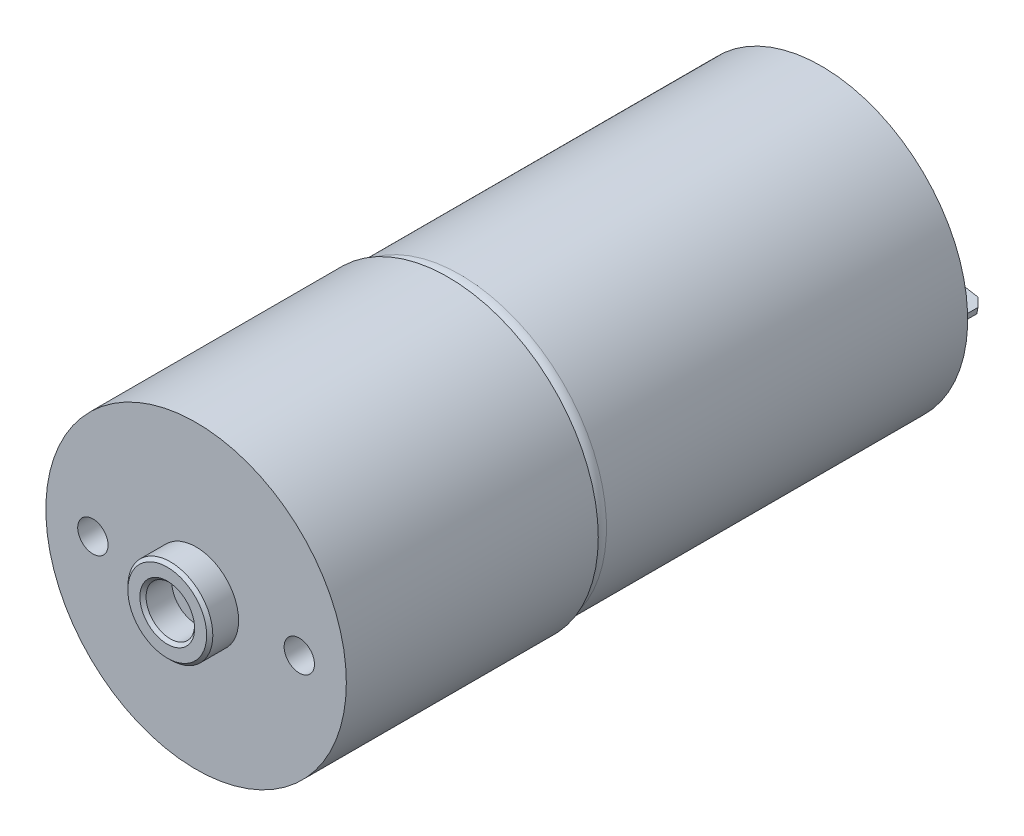
from build123d import *

# Parameters (mm, degrees)
SKETCH1_R                 = 12.05
BOSS_EXTRUDE1_DEPTH       = 30.75
FILLET2_R                 = 1
SKETCH2_R                 = 12.375
BOSS_EXTRUDE2_DEPTH       = 20.75
SKETCH3_R                 = 3.5
SKETCH3_R_2               = 2
BOSS_EXTRUDE3_DEPTH       = 2.375
CHAMFER1_SIZE             = 0.254
M3X0_5_TAPPED_HOLE1_D     = 2.5
M3X0_5_TAPPED_HOLE1_DEPTH = 7.5
M3X0_5_TAPPED_HOLE1_TIP   = 0.751075774
SKETCH7_R                 = 11.8
CUT_EXTRUDE1_DEPTH        = 0.762
SKETCH8_R                 = 4.5
BOSS_EXTRUDE4_DEPTH       = 0.254
BOSS_EXTRUDE4_TAPER       = 60
SKETCH9_R                 = 3.1875
BOSS_EXTRUDE5_DEPTH       = 2.413
FILLET1_R                 = 0.254
SKETCH10_R                = 1.524
BOSS_EXTRUDE6_DEPTH       = 1.016
BOSS_EXTRUDE7_DEPTH       = 3.175
SKETCH12_R                = 0.635
CUT_EXTRUDE2_DEPTH        = 3.175
CHAMFER2_SIZE             = 0.635
BOSS_EXTRUDE8_DEPTH       = 1.016
CUT_EXTRUDE3_DEPTH        = 10
CUT_EXTRUDE3_DEPTH_BACK   = 3
SKETCH15_R                = 1
BOSS_EXTRUDE9_DEPTH       = 0.5


with BuildPart() as part:
    # Sketch1 → Boss-Extrude1 (new body)
    with BuildSketch(Plane.XY):
        Circle(SKETCH1_R)
    extrude(amount=BOSS_EXTRUDE1_DEPTH)

    # Fillet2
    fillet2_edges = [part.edges().sort_by_distance(p)[0] for p in [
        (-12.05, 0, 30.75),
    ]]
    fillet(fillet2_edges, radius=FILLET2_R)

    # Sketch2 → Boss-Extrude2 (add)
    with BuildSketch(Plane.XY.offset(30.75)):
        Circle(SKETCH2_R)
    extrude(amount=BOSS_EXTRUDE2_DEPTH)

    # Sketch3 → Boss-Extrude3 (add)
    with BuildSketch(Plane.XY.offset(51.5)):
        Circle(SKETCH3_R)
        Circle(SKETCH3_R_2, mode=Mode.SUBTRACT)
    extrude(amount=BOSS_EXTRUDE3_DEPTH)

    # Chamfer1
    chamfer1_edges = [part.edges().sort_by_distance(p)[0] for p in [
        (-3.5, 0, 53.875),
        (-2, 0, 53.875),
    ]]
    chamfer(chamfer1_edges, length=CHAMFER1_SIZE)

    # M3x0.5 Tapped Hole1
    with Locations(Plane.XY.offset(51.5)):
        with Locations((-8.5, 0), (8.5, 0)):
            Hole(M3X0_5_TAPPED_HOLE1_D / 2, depth=M3X0_5_TAPPED_HOLE1_DEPTH)
            with Locations((0, 0, -(M3X0_5_TAPPED_HOLE1_DEPTH + M3X0_5_TAPPED_HOLE1_TIP / 2))):  # 118° drill point
                Cone(0, M3X0_5_TAPPED_HOLE1_D / 2, M3X0_5_TAPPED_HOLE1_TIP, mode=Mode.SUBTRACT)

    # Sketch7 → Cut-Extrude1 (cut)
    with BuildSketch(Plane(origin=(0, 0, 0), x_dir=(-1, 0, 0), z_dir=(0, 0, -1))):
        Circle(SKETCH7_R)
    extrude(amount=-CUT_EXTRUDE1_DEPTH, mode=Mode.SUBTRACT)

    # Sketch8 → Boss-Extrude4 (add)
    with BuildSketch(Plane(origin=(0, 0, 0.762), x_dir=(-1, 0, 0), z_dir=(0, 0, -1))):
        Circle(SKETCH8_R)
    extrude(amount=BOSS_EXTRUDE4_DEPTH, taper=BOSS_EXTRUDE4_TAPER)

    # Sketch9 → Boss-Extrude5 (add)
    with BuildSketch(Plane(origin=(0, 0, 0.508), x_dir=(-1, 0, 0), z_dir=(0, 0, -1))):
        Circle(SKETCH9_R)
    extrude(amount=BOSS_EXTRUDE5_DEPTH)

    # Fillet1
    fillet1_edges = [part.edges().sort_by_distance(p)[0] for p in [
        (3.1875, 0, 0.508),
        (3.1875, 0, -1.905),
    ]]
    fillet(fillet1_edges, radius=FILLET1_R)

    # Sketch10 → Boss-Extrude6 (add)
    with BuildSketch(Plane(origin=(0, 0, 0.762), x_dir=(-1, 0, 0), z_dir=(0, 0, -1))):
        with Locations((8.863269777, 1.562833599)):
            Circle(SKETCH10_R)
        with Locations((-8.863269777, -1.562833599)):
            Circle(SKETCH10_R)
    extrude(amount=BOSS_EXTRUDE6_DEPTH)

    # Sketch11 → Boss-Extrude7 (add)
    with BuildSketch(Plane(origin=(0, 0, -0.254), x_dir=(-1, 0, 0), z_dir=(0, 0, -1))):
        Polygon((-10.007333694, -2.022481295), (-7.630992586, -1.603468242), (-7.71920586, -1.103185903), (-10.095546968, -1.522198956), align=None)
        Polygon((7.71920586, 1.103185903), (10.095546968, 1.522198956), (10.007333694, 2.022481295), (7.630992586, 1.603468242), align=None)
    extrude(amount=BOSS_EXTRUDE7_DEPTH)

    # Sketch12 → Cut-Extrude2 (cut)
    with BuildSketch(Plane(origin=(0.044106637, 0.250141169, 0), x_dir=(0.984807753, -0.173648178, 0), z_dir=(0.173648178, 0.984807753, 0))):
        with Locations((-9, 2.159)):
            Circle(SKETCH12_R)
        with Locations((9, 2.159)):
            Circle(SKETCH12_R)
    extrude(amount=-CUT_EXTRUDE2_DEPTH, mode=Mode.SUBTRACT)

    # Chamfer2
    chamfer2_edges = [part.edges().sort_by_distance(p)[0] for p in [
        (-7.675099223, 1.353327073, -3.429),
        (-10.051440331, 1.772340125, -3.429),
        (10.051440331, -1.772340125, -3.429),
        (7.675099223, -1.353327073, -3.429),
    ]]
    chamfer(chamfer2_edges, length=CHAMFER2_SIZE)

    # Sketch13 → Boss-Extrude8 (add)
    with BuildSketch(Plane(origin=(0, 0, 0.762), x_dir=(-1, 0, 0), z_dir=(0, 0, -1))):
        with BuildLine():
            Line((-7.339269777, 2), (-7.339269777, -2))
            ThreePointArc((-7.339269777, -2), (-8.863269777, -3.524), (-10.387269777, -2))
            Line((-10.387269777, -2), (-10.387269777, 2))
            ThreePointArc((-10.387269777, 2), (-8.863269777, 3.524), (-7.339269777, 2))
        make_face()
        with BuildLine():
            Line((7.339269777, 2), (7.339269777, -2))
            ThreePointArc((7.339269777, -2), (8.863269777, -3.524), (10.387269777, -2))
            Line((10.387269777, -2), (10.387269777, 2))
            ThreePointArc((10.387269777, 2), (8.863269777, 3.524), (7.339269777, 2))
        make_face()
    extrude(amount=BOSS_EXTRUDE8_DEPTH)

    # Sketch14 → Cut-Extrude3 (cut, two sides)
    with BuildSketch(Plane(origin=(0, 0, 0.762), x_dir=(-1, 0, 0), z_dir=(0, 0, -1))) as cut_extrude3_sk:
        with BuildLine():
            ThreePointArc((-4.113620668, 2.375), (-4.75, 0), (-4.113620668, -2.375))
            ThreePointArc((-4.113620668, -2.375), (-3.772114317, -2.466506351), (-3.680607966, -2.125))
            ThreePointArc((-3.680607966, -2.125), (-4.25, 0), (-3.680607966, 2.125))
            ThreePointArc((-3.680607966, 2.125), (-3.772114317, 2.466506351), (-4.113620668, 2.375))
        make_face()
        with BuildLine():
            ThreePointArc((4.113620668, -2.375), (4.75, 0), (4.113620668, 2.375))
            ThreePointArc((4.113620668, 2.375), (3.772114317, 2.466506351), (3.680607966, 2.125))
            ThreePointArc((3.680607966, 2.125), (4.25, 0), (3.680607966, -2.125))
            ThreePointArc((3.680607966, -2.125), (3.772114317, -2.466506351), (4.113620668, -2.375))
        make_face()
    extrude(amount=CUT_EXTRUDE3_DEPTH, mode=Mode.SUBTRACT)
    extrude(cut_extrude3_sk.sketch, amount=-CUT_EXTRUDE3_DEPTH_BACK, mode=Mode.SUBTRACT)

    # Sketch15 → Boss-Extrude9 (add)
    with BuildSketch(Plane(origin=(0, 0, 0.762), x_dir=(-1, 0, 0), z_dir=(0, 0, -1))):
        with Locations((-8.191520443, 5.735764364)):
            Circle(SKETCH15_R)
        with Locations((8.191520443, 5.735764364)):
            Circle(SKETCH15_R)
        with Locations((8.191520443, -5.735764364)):
            Circle(SKETCH15_R)
        with Locations((-8.191520443, -5.735764364)):
            Circle(SKETCH15_R)
    extrude(amount=BOSS_EXTRUDE9_DEPTH)


solid = part.part
